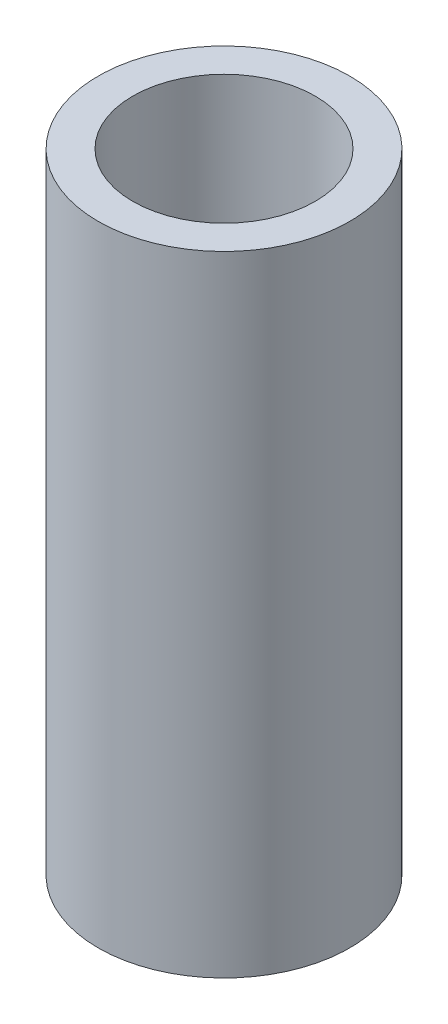
from build123d import *

# Parameters (mm, degrees)
SKETCH1_R           = 2
SKETCH1_R_2         = 1.45
BOSS_EXTRUDE1_DEPTH = 10


with BuildPart() as part:
    # Sketch1 → Boss-Extrude1 (new body)
    with BuildSketch(Plane(origin=(0, 0, 0), x_dir=(1, 0, 0), z_dir=(0, 1, 0))):
        Circle(SKETCH1_R)
        Circle(SKETCH1_R_2, mode=Mode.SUBTRACT)
    extrude(amount=BOSS_EXTRUDE1_DEPTH)


solid = part.part
